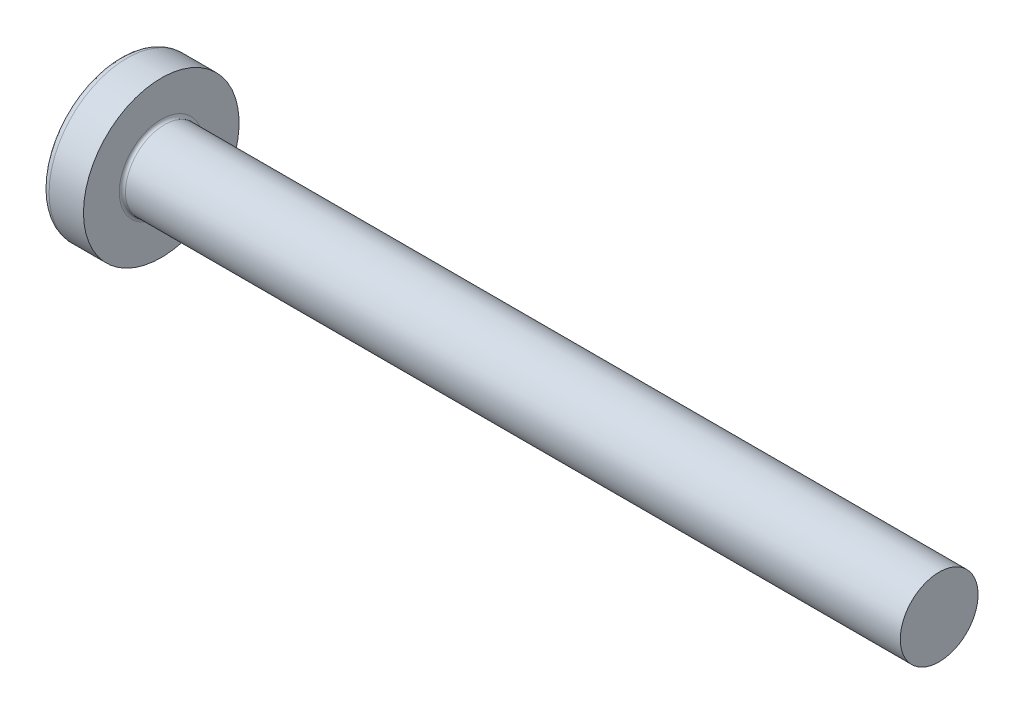
from build123d import *

# Parameters (mm, degrees)
FILLET1_R    = 0.1
SKETCH3_W    = 0.74
SKETCH3_H    = 2.6
SKETCH4_W    = 0.74
SKETCH4_H    = 1.104255426
RECPAT_COUNT = 2
RECPAT_ANGLE = 90


with BuildPart() as part:
    # BodySke → Base-Revolve (revolve)
    with BuildSketch(Plane.XY):
        with BuildLine():
            Line((2.1, 1.25), (2.1, 2.5))
            Line((2.1, 2.5), (0.99500416, 2.5))
            ThreePointArc((0.99500416, 2.5), (0.88781572, 2.474733878), (0.803195915, 2.404255319))
            ThreePointArc((0.803195915, 2.404255319), (0.206109099, 1.267435138), (0, 0))
            Line((0, 0), (27.1, 0))
            Line((27.1, 0), (27.1, 1.25))
            Line((27.1, 1.25), (2.1, 1.25))
        make_face()
    revolve(axis=Axis((-25.4, 0, 0), (1, 0, 0)))

    # Fillet1
    fillet1_edges = [part.edges().sort_by_distance(p)[0] for p in [
        (2.1, -1.25, 0),
    ]]
    fillet(fillet1_edges, radius=FILLET1_R)

    # Sketch3 → Recess section 0
    with BuildSketch(Plane(origin=(0, 0, 0), x_dir=(0, 0, -1), z_dir=(1, 0, 0))):
        Rectangle(SKETCH3_W, SKETCH3_H)
    # Sketch4 → Recess section 1
    with BuildSketch(Plane(origin=(1.5, 0, 0), x_dir=(0, 0, -1), z_dir=(1, 0, 0))):
        Rectangle(SKETCH4_W, SKETCH4_H)
    recess = loft(mode=Mode.SUBTRACT)

    # RecPat: Recess ×2 about axis
    recpat_axis = Axis((0, 0, 0), (1, 0, 0))
    for i in range(1, RECPAT_COUNT):
        add(recess.rotate(recpat_axis, i * RECPAT_ANGLE / (RECPAT_COUNT - 1)), mode=Mode.SUBTRACT)

    # RecCorSke → RecessCore (revolve, cut)
    with BuildSketch(Plane.XY):
        Polygon((0, 0), (0, 0.660890218), (1.5, 0.556), (1.680655351, 0), align=None)
    revolve(axis=Axis((-3.175, 0, 0), (1, 0, 0)), mode=Mode.SUBTRACT)


solid = part.part
